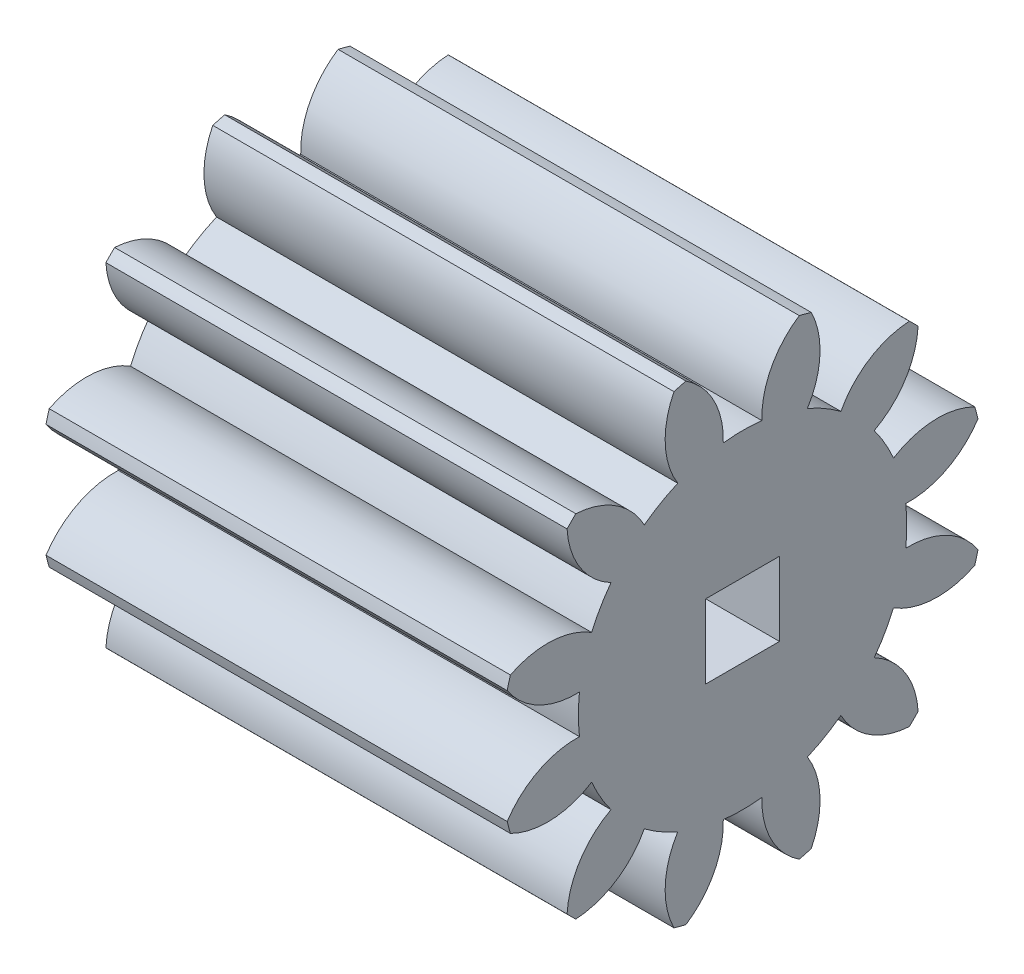
from build123d import *

# Parameters (mm, degrees)
BASPROSKE_W        = 20
BASPROSKE_H        = 10.5
TOOTHCUT_DEPTH     = 25.909837414
TEETHCUTS_COUNT    = 12
TEETHCUTS_ANGLE    = 330
BORSKE_R           = 0.5
BORE_DEPTH         = 50.0000508
SKETCH1_W          = 3.2
SKETCH1_H          = 3.2
CUT_EXTRUDE1_DEPTH = 30


with BuildPart() as part:
    # BasProSke → Base-Revolve (revolve)
    with BuildSketch(Plane(origin=(0, 0, 0), x_dir=(1, 0, 0), z_dir=(0, 1, 0)), mode=Mode.PRIVATE) as base_revolve_sk:
        with Locations((10, 5.25)):
            Rectangle(BASPROSKE_W, BASPROSKE_H)
    revolve(base_revolve_sk.sketch.rotate(Axis((-10, 0, 0), (1, 0, 0)), 180), axis=Axis((-10, 0, 0), (1, 0, 0)))

    # TooCutSke → ToothCut (cut, through all)
    with BuildSketch(Plane(origin=(0, 0, 0), x_dir=(0, 0, -1), z_dir=(1, 0, 0))):
        with BuildLine():
            ThreePointArc((0.837751456, 7.074570552), (0, 7.124), (-0.837751456, 7.074570552))
            ThreePointArc((-0.837751456, 7.074570552), (-1.245380016, 8.868946541), (-2.486473743, 10.227487154))
            ThreePointArc((-2.486473743, 10.227487154), (0, 10.5254), (2.486473743, 10.227487154))
            ThreePointArc((2.486473743, 10.227487154), (1.245380016, 8.868946541), (0.837751456, 7.074570552))
        make_face()
    toothcut = extrude(amount=TOOTHCUT_DEPTH, mode=Mode.SUBTRACT)

    # TeethCuts: ToothCut ×12 about axis
    teethcuts_axis = Axis((-10, 0, 0), (1, 0, 0))
    for i in range(1, TEETHCUTS_COUNT):
        add(toothcut.rotate(teethcuts_axis, i * TEETHCUTS_ANGLE / (TEETHCUTS_COUNT - 1)), mode=Mode.SUBTRACT)

    # BorSke → Bore (cut, symmetric)
    with BuildSketch(Plane(origin=(0, 0, 0), x_dir=(0, 0, -1), z_dir=(1, 0, 0))):
        with Locations(Location((0, 0, 0), (0, 0, 180))):
            Circle(BORSKE_R)
    extrude(amount=BORE_DEPTH, both=True, mode=Mode.SUBTRACT)

    # Sketch1 → Cut-Extrude1 (cut)
    with BuildSketch(Plane(origin=(20, 0, 0), x_dir=(0, 0, -1), z_dir=(1, 0, 0))):
        Rectangle(SKETCH1_W, SKETCH1_H)
    extrude(amount=-CUT_EXTRUDE1_DEPTH, mode=Mode.SUBTRACT)


solid = part.part
